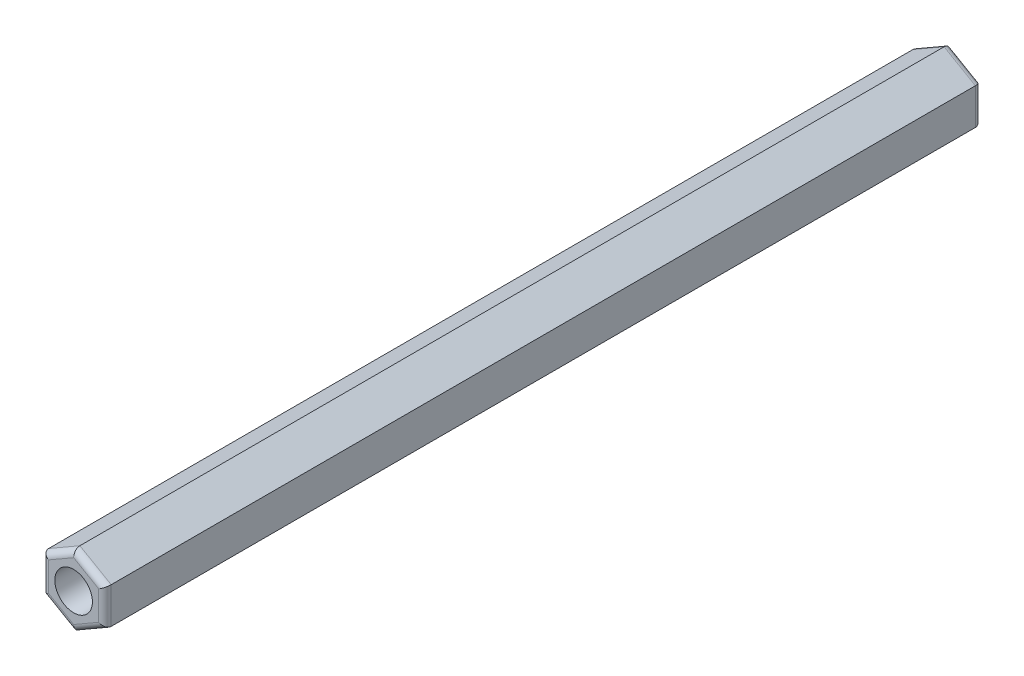
from build123d import *

# Parameters (mm, degrees)
RESSALTO_EXTRUS_O1_DEPTH = 70
FILETE1_R                = 0.5
ESBO_O2_R                = 1.5
CORTE_EXTRUS_O1_DEPTH    = 71


with BuildPart() as part:
    # Esboço1 → Ressalto-extrusão1 (new body)
    with BuildSketch(Plane(origin=(0, 0, 0), x_dir=(-1, 0, 0), z_dir=(0, 0, -1))):
        Polygon((67.502122675, -1.443375673), (70.002122675, -2.886751346), (72.502122675, -1.443375673), (72.502122675, 1.443375673), (70.002122675, 2.886751346), (67.502122675, 1.443375673), align=None)
    extrude(amount=-RESSALTO_EXTRUS_O1_DEPTH)

    # Filete1
    filete1_edges = [part.edges().sort_by_distance(p)[0] for p in [
        (-71.252122675, -2.165063509, 70),
        (-72.502122675, 0, 70),
        (-71.252122675, 2.165063509, 70),
        (-68.752122675, 2.165063509, 70),
        (-67.502122675, 0, 70),
        (-68.752122675, 2.165063509, 0),
        (-71.252122675, 2.165063509, 0),
        (-72.502122675, 0, 0),
        (-71.252122675, -2.165063509, 0),
        (-68.752122675, -2.165063509, 0),
        (-67.502122675, 0, 0),
        (-68.752122675, -2.165063509, 70),
    ]]
    fillet(filete1_edges, radius=FILETE1_R)

    # Esboço2 → Corte-extrusão1 (cut, through all)
    with BuildSketch(Plane.XY.offset(70)):
        with Locations((-70.002122675, 0)):
            Circle(ESBO_O2_R)
    extrude(amount=-CORTE_EXTRUS_O1_DEPTH, mode=Mode.SUBTRACT)


solid = part.part
